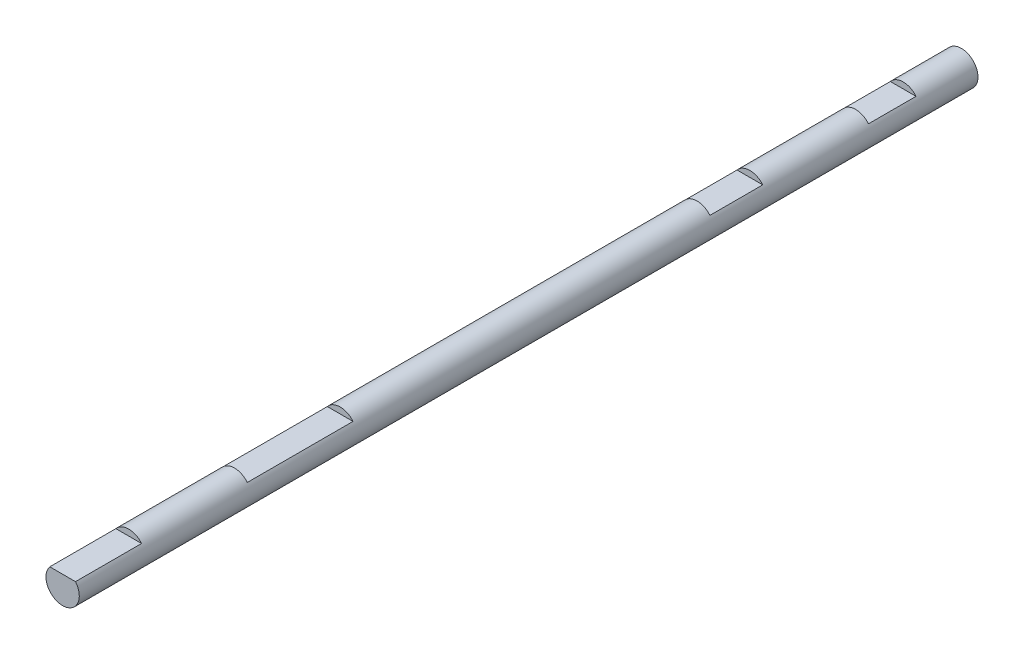
from build123d import *

# Parameters (mm, degrees)
SKETCH1_R           = 4
BOSS_EXTRUDE1_DEPTH = 215.9
SKETCH2_W           = 12.7
SKETCH2_H           = 1.46
SKETCH2_W_2         = 25.4
SKETCH2_W_3         = 15.875
SKETCH2_W_4         = 11.43
CUT_EXTRUDE1_DEPTH  = 6.35


with BuildPart() as part:
    # Sketch1 → Boss-Extrude1 (new body)
    with BuildSketch(Plane.XY):
        Circle(SKETCH1_R)
    extrude(amount=BOSS_EXTRUDE1_DEPTH)

    # Sketch2 → Cut-Extrude1 (cut, symmetric)
    with BuildSketch(Plane(origin=(0, 0, 0), x_dir=(0, 0, -1), z_dir=(1, 0, 0))):
        with Locations((-57.15, 3.27)):
            Rectangle(SKETCH2_W, SKETCH2_H)
        with Locations((-161.925, 3.27)):
            Rectangle(SKETCH2_W_2, SKETCH2_H)
        with Locations((-207.9625, 3.27)):
            Rectangle(SKETCH2_W_3, SKETCH2_H)
        with Locations((-19.685, 3.27)):
            Rectangle(SKETCH2_W_4, SKETCH2_H)
    extrude(amount=CUT_EXTRUDE1_DEPTH, both=True, mode=Mode.SUBTRACT)


solid = part.part
